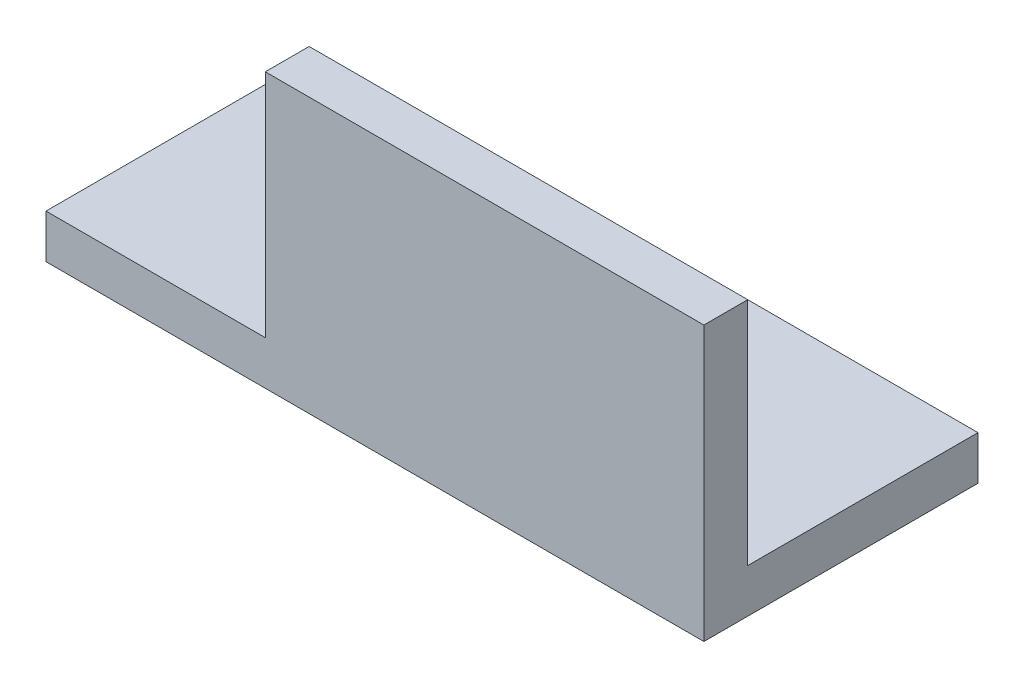
from build123d import *

# Parameters (mm, degrees)
EXTRUDE_1_DEPTH     = 60
SKETCH_2_W          = 20
SKETCH_2_H          = 21
CUT_EXTRUDE_1_DEPTH = 26


with BuildPart() as part:
    # Эскиз1 → Вытянуть-Тонкостенный1 (new body)
    with BuildSketch(Plane(origin=(0, 0, 0), x_dir=(0, 0, -1), z_dir=(1, 0, 0))):
        Polygon((0, 25), (0, 0), (25, 0), (25, 4), (4, 4), (4, 25), align=None)
    extrude(amount=EXTRUDE_1_DEPTH)

    # Эскиз2 → Вырез-Вытянуть1 (cut, through all)
    with BuildSketch(Plane.XY):
        with Locations((10, 14.5)):
            Rectangle(SKETCH_2_W, SKETCH_2_H)
    extrude(amount=-CUT_EXTRUDE_1_DEPTH, mode=Mode.SUBTRACT)


solid = part.part
